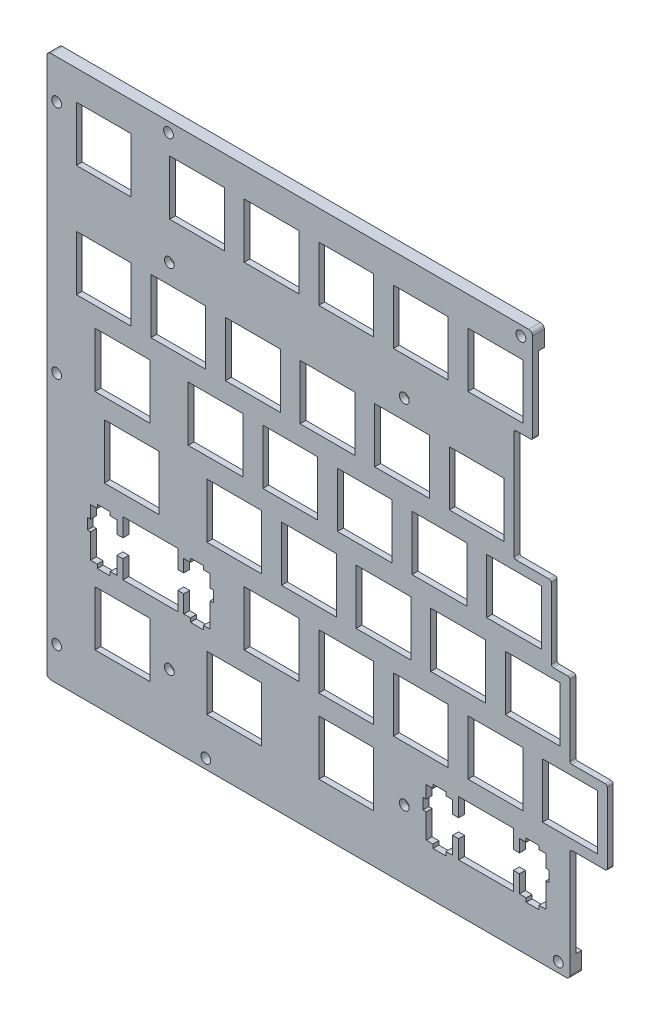
from build123d import *

# Parameters (mm, degrees)
MODEL_W                = 13.99954
MODEL_H                = 13.99946
MODEL_W_2              = 13.9993
MODEL_H_2              = 13.9994
MODEL_W_3              = 14
MODEL_W_4              = 14.00087
MODEL_H_3              = 13.9993
MODEL_W_5              = 13.9998
MODEL_W_6              = 13.999
MODEL_W_7              = 13.99955
MODEL_W_8              = 14.0007
MODEL_H_4              = 13.999
EXTRUDE_1_DEPTH        = 1.5
SKETCH_5_W             = 128.5879154
SKETCH_5_H             = 1.5
EXTRUDE_3_DEPTH        = 4.76
EXTRUDE_2_DEPTH        = 3
SKETCH_3_R             = 1.25
CUT_EXTRUDE_1_DEPTH    = 3
PATTERN_LINEAR_1_COUNT = 2
PATTERN_LINEAR_1_PITCH = 90
SKETCH_4_R             = 1.25
CUT_EXTRUDE_2_DEPTH    = 3
PATTERN_LINEAR_2_COUNT = 3
PATTERN_LINEAR_2_PITCH = 60
FILLET_1_R             = 1
FILLET_2_R             = 0.5
SKETCH_6_R             = 1.25
CUT_EXTRUDE_3_DEPTH    = 10


with BuildPart() as part:
    # Model → 凸台-拉伸1 (new body)
    with BuildSketch(Plane.XY):
        Polygon((0.0950846, 124.083), (119.158, 124.083), (119.158, 105.033), (114.395, 105.033), (114.395, 76.453), (123.92, 76.453), (123.92, 57.403), (128.683, 57.403), (128.683, 38.353), (138.208, 38.353), (138.208, 19.303), (128.683, 19.303), (128.683, 0.257693), (0.0950846, 0.257693), align=None)
        Polygon((100.251, 16.7831), (100.251, 12.0826), (98.7256, 12.0826), (98.7256, 15.3128), (97.0001, 15.3128), (97.0001, 16.2333), (93.701, 16.2333), (93.701, 15.3128), (91.9759, 15.3128), (91.9759, 12.0826), (91.1504, 12.0826), (91.1504, 9.28384), (91.9759, 9.28384), (91.9759, 3.01377), (93.701, 3.01377), (93.701, 2.03261), (97.0001, 2.03261), (97.0001, 3.01377), (98.7256, 3.01377), (98.7256, 7.48273), (100.251, 7.48273), (100.251, 2.78364), (114.25, 2.78364), (114.25, 7.48273), (115.776, 7.48273), (115.776, 3.01377), (117.5, 3.01377), (117.5, 2.03261), (120.8, 2.03261), (120.8, 3.01377), (122.525, 3.01377), (122.525, 9.28384), (123.351, 9.28384), (123.351, 12.0826), (122.525, 12.0826), (122.525, 15.3128), (120.8, 15.3128), (120.8, 16.2333), (117.5, 16.2333), (117.5, 15.3128), (115.776, 15.3128), (115.776, 12.0826), (114.25, 12.0826), (114.25, 16.7831), align=None, mode=Mode.SUBTRACT)
        with Locations((14.38193, 9.78337)):
            Rectangle(MODEL_W, MODEL_H, mode=Mode.SUBTRACT)
        with Locations((42.95685, 9.78337)):
            Rectangle(MODEL_W_2, MODEL_H, mode=Mode.SUBTRACT)
        with Locations((71.53185, 9.78337)):
            Rectangle(MODEL_W_2, MODEL_H, mode=Mode.SUBTRACT)
        Polygon((14.5259, 35.833), (14.5259, 31.1326), (13.0004, 31.1326), (13.0004, 34.3628), (11.2751, 34.3628), (11.2751, 35.2834), (7.97609, 35.2834), (7.97609, 34.3628), (6.2508, 34.3628), (6.2508, 31.1326), (5.42533, 31.1326), (5.42533, 28.3338), (6.2508, 28.3338), (6.2508, 22.0638), (7.97609, 22.0638), (7.97609, 21.0826), (11.2751, 21.0826), (11.2751, 22.0638), (13.0004, 22.0638), (13.0004, 26.5327), (14.5259, 26.5327), (14.5259, 21.8336), (28.5254, 21.8336), (28.5254, 26.5327), (30.0509, 26.5327), (30.0509, 22.0638), (31.7748, 22.0638), (31.7748, 21.0826), (35.0752, 21.0826), (35.0752, 22.0638), (36.8004, 22.0638), (36.8004, 28.3338), (37.6259, 28.3338), (37.6259, 31.1326), (36.8004, 31.1326), (36.8004, 34.3628), (35.0752, 34.3628), (35.0752, 35.2834), (31.7748, 35.2834), (31.7748, 34.3628), (30.0509, 34.3628), (30.0509, 31.1326), (28.5254, 31.1326), (28.5254, 35.833), align=None, mode=Mode.SUBTRACT)
        with Locations((52.48185, 28.8333)):
            Rectangle(MODEL_W_2, MODEL_H_2, mode=Mode.SUBTRACT)
        with Locations((71.53185, 28.8333)):
            Rectangle(MODEL_W_2, MODEL_H_2, mode=Mode.SUBTRACT)
        with Locations((90.58185, 28.8333)):
            Rectangle(MODEL_W_2, MODEL_H_2, mode=Mode.SUBTRACT)
        with Locations((109.632, 28.8333)):
            Rectangle(MODEL_W_3, MODEL_H_2, mode=Mode.SUBTRACT)
        with Locations((128.682, 28.8333)):
            Rectangle(MODEL_W_3, MODEL_H_2, mode=Mode.SUBTRACT)
        with Locations((16.762465, 47.88345)):
            Rectangle(MODEL_W_4, MODEL_H_3, mode=Mode.SUBTRACT)
        with Locations((42.95685, 47.88345)):
            Rectangle(MODEL_W_2, MODEL_H_3, mode=Mode.SUBTRACT)
        with Locations((62.00685, 47.88345)):
            Rectangle(MODEL_W_2, MODEL_H_3, mode=Mode.SUBTRACT)
        with Locations((81.05685, 47.88345)):
            Rectangle(MODEL_W_2, MODEL_H_3, mode=Mode.SUBTRACT)
        with Locations((100.1071, 47.88345)):
            Rectangle(MODEL_W_5, MODEL_H_3, mode=Mode.SUBTRACT)
        with Locations((119.157, 47.88345)):
            Rectangle(MODEL_W_3, MODEL_H_3, mode=Mode.SUBTRACT)
        with Locations((14.38193, 66.93345)):
            Rectangle(MODEL_W, MODEL_H_3, mode=Mode.SUBTRACT)
        with Locations((38.19435, 66.93345)):
            Rectangle(MODEL_W_2, MODEL_H_3, mode=Mode.SUBTRACT)
        with Locations((57.24435, 66.93345)):
            Rectangle(MODEL_W_2, MODEL_H_3, mode=Mode.SUBTRACT)
        with Locations((76.29435, 66.93345)):
            Rectangle(MODEL_W_2, MODEL_H_3, mode=Mode.SUBTRACT)
        with Locations((95.34435, 66.93345)):
            Rectangle(MODEL_W_2, MODEL_H_3, mode=Mode.SUBTRACT)
        with Locations((114.3945, 66.93345)):
            Rectangle(MODEL_W_6, MODEL_H_3, mode=Mode.SUBTRACT)
        with Locations((9.619425, 85.98345)):
            Rectangle(MODEL_W_7, MODEL_H_3, mode=Mode.SUBTRACT)
        with Locations((28.66935, 85.98345)):
            Rectangle(MODEL_W_2, MODEL_H_3, mode=Mode.SUBTRACT)
        with Locations((47.71935, 85.98345)):
            Rectangle(MODEL_W_2, MODEL_H_3, mode=Mode.SUBTRACT)
        with Locations((66.76935, 85.98345)):
            Rectangle(MODEL_W_2, MODEL_H_3, mode=Mode.SUBTRACT)
        with Locations((85.81935, 85.98345)):
            Rectangle(MODEL_W_2, MODEL_H_3, mode=Mode.SUBTRACT)
        with Locations((104.86865, 85.98345)):
            Rectangle(MODEL_W_8, MODEL_H_3, mode=Mode.SUBTRACT)
        with Locations((9.619425, 114.5585)):
            Rectangle(MODEL_W_7, MODEL_H_4, mode=Mode.SUBTRACT)
        with Locations((33.43185, 114.5585)):
            Rectangle(MODEL_W_2, MODEL_H_4, mode=Mode.SUBTRACT)
        with Locations((52.48185, 114.5585)):
            Rectangle(MODEL_W_2, MODEL_H_4, mode=Mode.SUBTRACT)
        with Locations((71.53185, 114.5585)):
            Rectangle(MODEL_W_2, MODEL_H_4, mode=Mode.SUBTRACT)
        with Locations((90.58185, 114.5585)):
            Rectangle(MODEL_W_2, MODEL_H_4, mode=Mode.SUBTRACT)
        with Locations((109.632, 114.5585)):
            Rectangle(MODEL_W_3, MODEL_H_4, mode=Mode.SUBTRACT)
    extrude(amount=EXTRUDE_1_DEPTH)

    # 草图5 → 凸台-拉伸3 (add)
    with BuildSketch(Plane.XZ.offset(-0.257693)):
        with Locations((64.3890423, 0.75)):
            Rectangle(SKETCH_5_W, SKETCH_5_H)
    extrude(amount=EXTRUDE_3_DEPTH)

    # 草图2 → 凸台-拉伸2 (add)
    with BuildSketch(Plane.XY.offset(1.5)):
        Polygon((119.158, 124.083), (0.0950846, 124.083), (0.0950846, -4.502307), (128.683, -4.502307), (128.683, -9.502307), (-4.9049154, -9.502307), (-4.9049154, 129.083), (119.158, 129.083), align=None)
    extrude(amount=-EXTRUDE_2_DEPTH)

    # 草图3 → 切除-拉伸1 (cut)
    with BuildSketch(Plane.XY.offset(1.5)):
        with Locations((125.683, -7.002307)):
            Circle(SKETCH_3_R)
        with Locations((116.158, 126.583)):
            Circle(SKETCH_3_R)
    cut_extrude_1 = extrude(amount=-CUT_EXTRUDE_1_DEPTH, mode=Mode.SUBTRACT)

    # 阵列(线性)1: 切除-拉伸1 ×2
    with Locations(*[(-i * PATTERN_LINEAR_1_PITCH, 0, 0) for i in range(1, PATTERN_LINEAR_1_COUNT)]):
        add(cut_extrude_1, mode=Mode.SUBTRACT)

    # 草图4 → 切除-拉伸2 (cut)
    with BuildSketch(Plane.XY.offset(1.5)):
        with Locations((-2.4049154, 119.083)):
            Circle(SKETCH_4_R)
    cut_extrude_2 = extrude(amount=-CUT_EXTRUDE_2_DEPTH, mode=Mode.SUBTRACT)

    # 阵列(线性)2: 切除-拉伸2 ×3
    with Locations(*[(0, -i * PATTERN_LINEAR_2_PITCH, 0) for i in range(1, PATTERN_LINEAR_2_COUNT)]):
        add(cut_extrude_2, mode=Mode.SUBTRACT)

    # 圆角1
    fillet_1_edges = [part.edges().sort_by_distance(p)[0] for p in [
        (119.158, 129.083, 0),
        (128.683, -9.502307, 0),
        (-4.9049154, -9.502307, 0),
        (-4.9049154, 129.083, 0),
    ]]
    fillet(fillet_1_edges, radius=FILLET_1_R)

    # 圆角2
    fillet_2_edges = [part.edges().sort_by_distance(p)[0] for p in [
        (119.158, 105.033, 0.75),
        (114.395, 105.033, 0.75),
        (114.395, 76.453, 0.75),
        (123.92, 76.453, 0.75),
        (123.92, 57.403, 0.75),
        (128.683, 57.403, 0.75),
        (128.683, 38.353, 0.75),
        (138.208, 38.353, 0.75),
        (138.208, 19.303, 0.75),
        (128.683, 19.303, 0.75),
    ]]
    fillet(fillet_2_edges, radius=FILLET_2_R)

    # 草图6 → 切除-拉伸3 (cut)
    with BuildSketch(Plane.XY.offset(1.5)):
        with Locations((26.3817, 7.9831)):
            Circle(SKETCH_6_R)
        with Locations((86.3817, 7.9831)):
            Circle(SKETCH_6_R)
        with Locations((86.3817, 97.9831)):
            Circle(SKETCH_6_R)
        with Locations((26.3817, 97.9831)):
            Circle(SKETCH_6_R)
    extrude(amount=-CUT_EXTRUDE_3_DEPTH, mode=Mode.SUBTRACT)


solid = part.part
